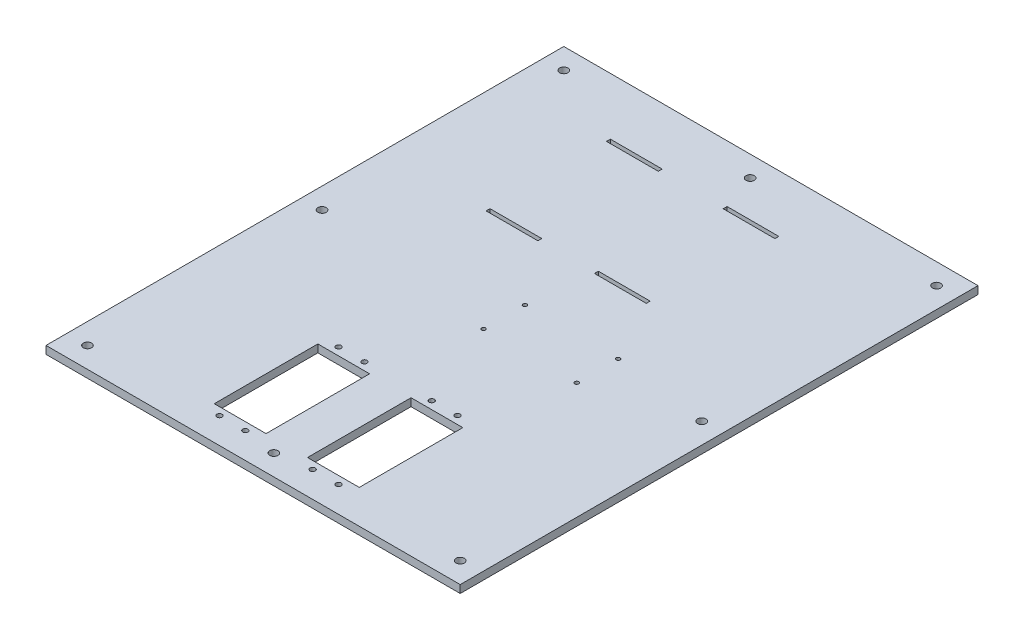
from build123d import *

# Parameters (mm, degrees)
SKETCH_1_W          = 160
SKETCH_1_H          = 200
EXTRUDE_2_DEPTH     = 3
SKETCH_2_R          = 1
SKETCH_2_W          = 20
SKETCH_2_H          = 40
CUT_EXTRUDE_1_DEPTH = 3
SKETCH_3_R          = 0.75
CUT_EXTRUDE_2_DEPTH = 10
SKETCH_4_R          = 1.6
CUT_EXTRUDE_3_DEPTH = 10
SKETCH_5_W          = 20
SKETCH_5_H          = 1.5
CUT_EXTRUDE_4_DEPTH = 10


with BuildPart() as part:
    # 草图1 → 凸台-拉伸2 (new body)
    with BuildSketch(Plane(origin=(0, 0, 0), x_dir=(1, 0, 0), z_dir=(0, 1, 0))):
        Rectangle(SKETCH_1_W, SKETCH_1_H)
    extrude(amount=EXTRUDE_2_DEPTH)

    # 草图2 → 切除-拉伸1 (cut)
    with BuildSketch(Plane(origin=(0, 3, 0), x_dir=(1, 0, 0), z_dir=(0, 1, 0))):
        with Locations((23, -90)):
            Circle(SKETCH_2_R)
        with Locations((13, -44)):
            Circle(SKETCH_2_R)
        with Locations((-23, -90)):
            Circle(SKETCH_2_R)
        with Locations((-23, -44)):
            Circle(SKETCH_2_R)
        with Locations((-13, -44)):
            Circle(SKETCH_2_R)
        with Locations((-13, -90)):
            Circle(SKETCH_2_R)
        with Locations((13, -90)):
            Circle(SKETCH_2_R)
        with Locations((22.939303547, -44)):
            Circle(SKETCH_2_R)
        with Locations((-18, -67)):
            Rectangle(SKETCH_2_W, SKETCH_2_H)
        with Locations((18, -67)):
            Rectangle(SKETCH_2_W, SKETCH_2_H)
    extrude(amount=-CUT_EXTRUDE_1_DEPTH, mode=Mode.SUBTRACT)

    # 草图3 → 切除-拉伸2 (cut)
    with BuildSketch(Plane(origin=(0, 3, 0), x_dir=(1, 0, 0), z_dir=(0, 1, 0))):
        with Locations((35, -10)):
            Circle(SKETCH_3_R)
        with Locations((35, 6)):
            Circle(SKETCH_3_R)
        with Locations((-1, -10)):
            Circle(SKETCH_3_R)
        with Locations((-1, 6)):
            Circle(SKETCH_3_R)
    extrude(amount=-CUT_EXTRUDE_2_DEPTH, mode=Mode.SUBTRACT)

    # 草图4 → 切除-拉伸3 (cut)
    with BuildSketch(Plane(origin=(0, 3, 0), x_dir=(1, 0, 0), z_dir=(0, 1, 0))):
        with Locations((72, 1.284440395)):
            Circle(SKETCH_4_R)
        with Locations((-72, -1.368262766)):
            Circle(SKETCH_4_R)
        with Locations((72, 92)):
            Circle(SKETCH_4_R)
        with Locations((-72, 92)):
            Circle(SKETCH_4_R)
        with Locations((-72, -92)):
            Circle(SKETCH_4_R)
        with Locations((72, -92)):
            Circle(SKETCH_4_R)
        with Locations((0, -92)):
            Circle(SKETCH_4_R)
        with Locations((0, 92)):
            Circle(SKETCH_4_R)
    extrude(amount=-CUT_EXTRUDE_3_DEPTH, mode=Mode.SUBTRACT)

    # 草图5 → 切除-拉伸4 (cut)
    with BuildSketch(Plane(origin=(0, 3, 0), x_dir=(1, 0, 0), z_dir=(0, 1, 0))):
        with Locations((-30, 77.25)):
            Rectangle(SKETCH_5_W, SKETCH_5_H)
        with Locations((-30, 30.75)):
            Rectangle(SKETCH_5_W, SKETCH_5_H)
        with Locations((15.068831665, 77.25)):
            Rectangle(SKETCH_5_W, SKETCH_5_H)
        with Locations((11.85252458, 30.75)):
            Rectangle(SKETCH_5_W, SKETCH_5_H)
    extrude(amount=-CUT_EXTRUDE_4_DEPTH, mode=Mode.SUBTRACT)


solid = part.part
